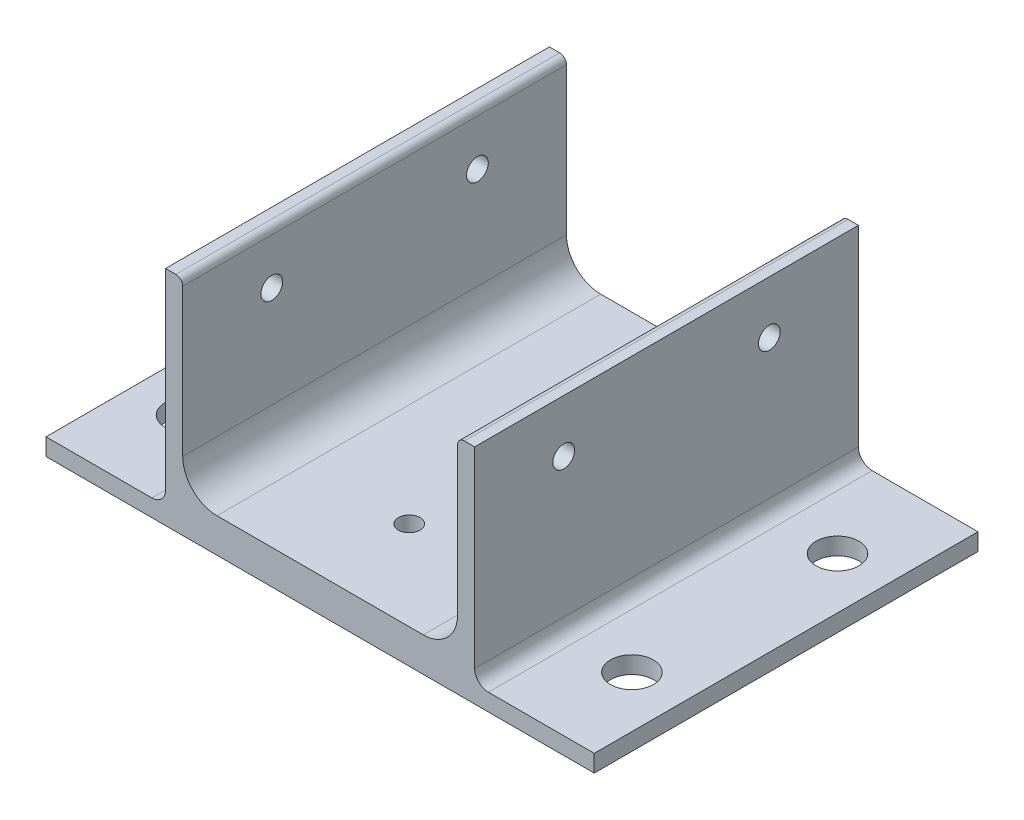
from build123d import *

# Parameters (mm, degrees)
BOSS_EXTRUDE1_DEPTH = 71.12
SKETCH4_W           = 9.4615
SKETCH4_H           = 3.175
CUT_EXTRUDE1_DEPTH  = 72.12
BOSS_EXTRUDE2_DEPTH = 71.12
FILLET2_R           = 6.35
FILLET4_R           = 1.27
SKETCH6_W           = 101.6
SKETCH6_H           = 71.12
BOSS_EXTRUDE3_DEPTH = 3.175
SKETCH7_R           = 2.0193
CUT_EXTRUDE2_DEPTH  = 80.4385
SKETCH8_R           = 2.0193
CUT_EXTRUDE3_DEPTH  = 42.275
SKETCH9_R           = 3.96875
CUT_EXTRUDE4_DEPTH  = 42.275
FILLET5_R           = 2.54
SKETCH10_R          = 5.08
CUT_EXTRUDE5_DEPTH  = 3.175


with BuildPart() as part:
    # Sketch3 → Boss-Extrude1 (new body)
    with BuildSketch(Plane.XY):
        with BuildLine():
            Line((0, 6.35), (0, 33.655))
            ThreePointArc((0, 33.655), (-0.371974388, 34.553025612), (-1.27, 34.925))
            Line((-1.27, 34.925), (-3.175, 34.925))
            Line((-3.175, 34.925), (-3.175, 0))
            Line((-3.175, 0), (-3.175, -3.175))
            Line((-3.175, -3.175), (34.925, -3.175))
            Line((34.925, -3.175), (34.925, -1.27))
            ThreePointArc((34.925, -1.27), (34.553025612, -0.371974388), (33.655, 0))
            Line((33.655, 0), (6.35, 0))
            ThreePointArc((6.35, 0), (1.859871939, 1.859871939), (0, 6.35))
        make_face()
    extrude(amount=BOSS_EXTRUDE1_DEPTH)

    # Sketch4 → Cut-Extrude1 (cut, through all)
    with BuildSketch(Plane(origin=(0, 0, 0), x_dir=(-1, 0, 0), z_dir=(0, 0, -1))):
        with Locations((-30.19425, -1.5875)):
            Rectangle(SKETCH4_W, SKETCH4_H)
    extrude(amount=-CUT_EXTRUDE1_DEPTH, mode=Mode.SUBTRACT)

    # Sketch5 → Boss-Extrude2 (add)
    with BuildSketch(Plane(origin=(0, 0, 0), x_dir=(-1, 0, 0), z_dir=(0, 0, -1))):
        Polygon((-25.4635, -3.175), (-54.102, -3.175), (-54.102, 34.925), (-50.927, 34.925), (-50.927, 0), (-25.4635, 0), align=None)
    extrude(amount=-BOSS_EXTRUDE2_DEPTH)

    # Fillet2
    fillet2_edges = [part.edges().sort_by_distance(p)[0] for p in [
        (50.927, 0, 35.56),
    ]]
    fillet(fillet2_edges, radius=FILLET2_R)

    # Fillet4
    fillet4_edges = [part.edges().sort_by_distance(p)[0] for p in [
        (50.927, 34.925, 35.56),
    ]]
    fillet(fillet4_edges, radius=FILLET4_R)

    # Sketch6 → Boss-Extrude3 (add)
    with BuildSketch(Plane.XZ.offset(3.175)):
        with Locations((25.4635, 35.56)):
            Rectangle(SKETCH6_W, SKETCH6_H)
    extrude(amount=BOSS_EXTRUDE3_DEPTH)

    # Sketch7 → Cut-Extrude2 (cut, through all)
    with BuildSketch(Plane.ZY.offset(3.175)):
        with Locations((16.51, 25.146)):
            Circle(SKETCH7_R)
        with Locations((54.61, 25.146)):
            Circle(SKETCH7_R)
    extrude(amount=-CUT_EXTRUDE2_DEPTH, mode=Mode.SUBTRACT)

    # Sketch8 → Cut-Extrude3 (cut, through all)
    with BuildSketch(Plane.XZ.offset(6.35)):
        with Locations((25.4635, 16.51)):
            Circle(SKETCH8_R)
        with Locations((25.4635, 54.61)):
            Circle(SKETCH8_R)
    extrude(amount=-CUT_EXTRUDE3_DEPTH, mode=Mode.SUBTRACT)

    # Sketch9 → Cut-Extrude4 (cut, through all)
    with BuildSketch(Plane.XZ.offset(6.35)):
        with Locations((-15.8115, 16.51)):
            Circle(SKETCH9_R)
        with Locations((-15.8115, 54.61)):
            Circle(SKETCH9_R)
        with Locations((66.7385, 54.61)):
            Circle(SKETCH9_R)
        with Locations((66.7385, 16.51)):
            Circle(SKETCH9_R)
    extrude(amount=-CUT_EXTRUDE4_DEPTH, mode=Mode.SUBTRACT)

    # Fillet5
    fillet5_edges = [part.edges().sort_by_distance(p)[0] for p in [
        (-3.175, -3.175, 35.56),
        (54.102, -3.175, 35.56),
    ]]
    fillet(fillet5_edges, radius=FILLET5_R)

    # Sketch10 → Cut-Extrude5 (cut)
    with BuildSketch(Plane.XZ.offset(6.35)):
        with Locations((25.4635, 54.61)):
            Circle(SKETCH10_R)
        with Locations((25.4635, 16.51)):
            Circle(SKETCH10_R)
    extrude(amount=-CUT_EXTRUDE5_DEPTH, mode=Mode.SUBTRACT)


solid = part.part
